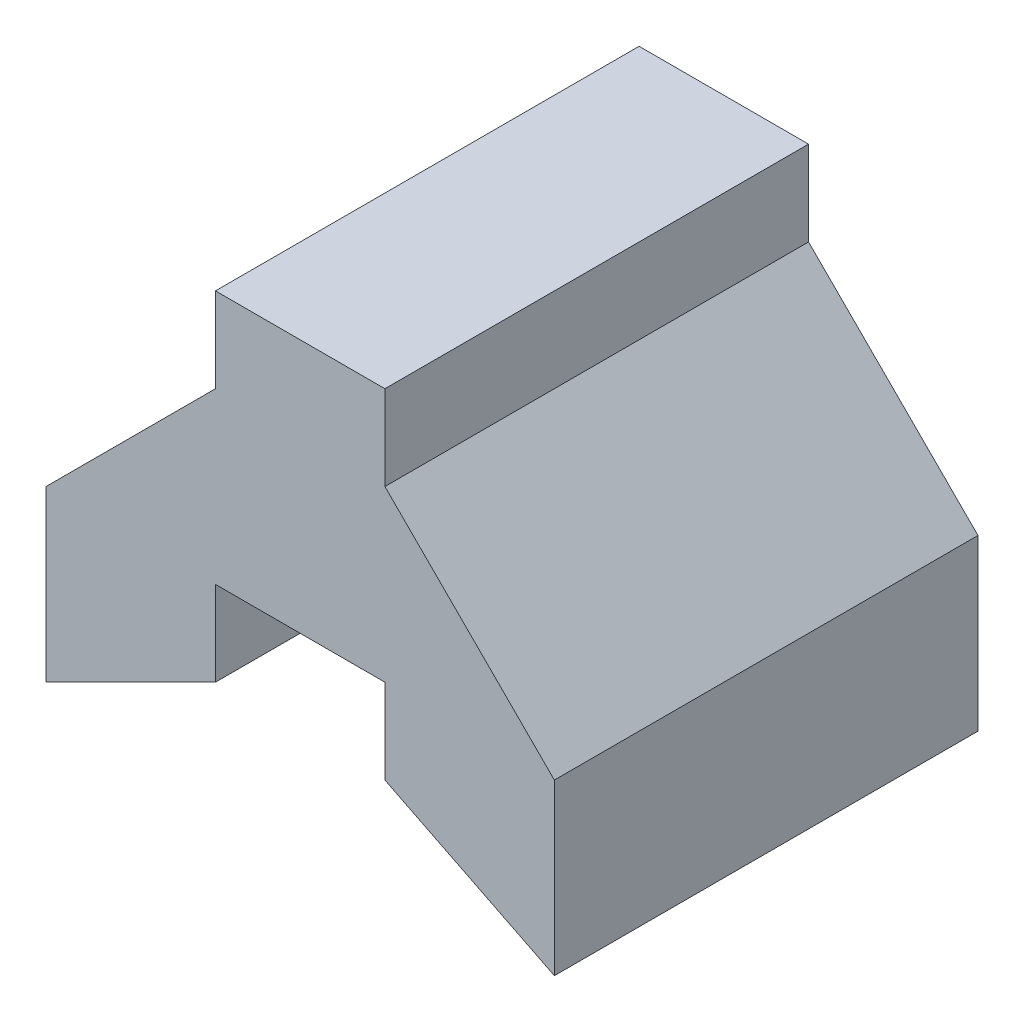
from build123d import *

# Parameters (mm, degrees)
BOSS_EXTRUDE1_DEPTH = 5
SKETCH3_W           = 2
SKETCH3_H           = 5.099019514
CUT_EXTRUDE3_DEPTH  = 2


with BuildPart() as part:
    # Sketch1 → Boss-Extrude1 (new body)
    with BuildSketch(Plane.XY):
        Polygon((0, 0), (-2, 0), (-4, -1), (-4, 1), (-2, 3), (-2, 4), (0, 4), (0, 3), (2, 1), (2, -1), align=None)
    extrude(amount=BOSS_EXTRUDE1_DEPTH)

    # Sketch3 → Cut-Extrude3 (cut)
    with BuildSketch(Plane(origin=(0, 0, 0), x_dir=(-1, 0, 0), z_dir=(0, -0.980580676, 0.196116135))):
        with Locations((1, -2.549509757)):
            Rectangle(SKETCH3_W, SKETCH3_H)
    extrude(amount=CUT_EXTRUDE3_DEPTH, mode=Mode.SUBTRACT)


solid = part.part
